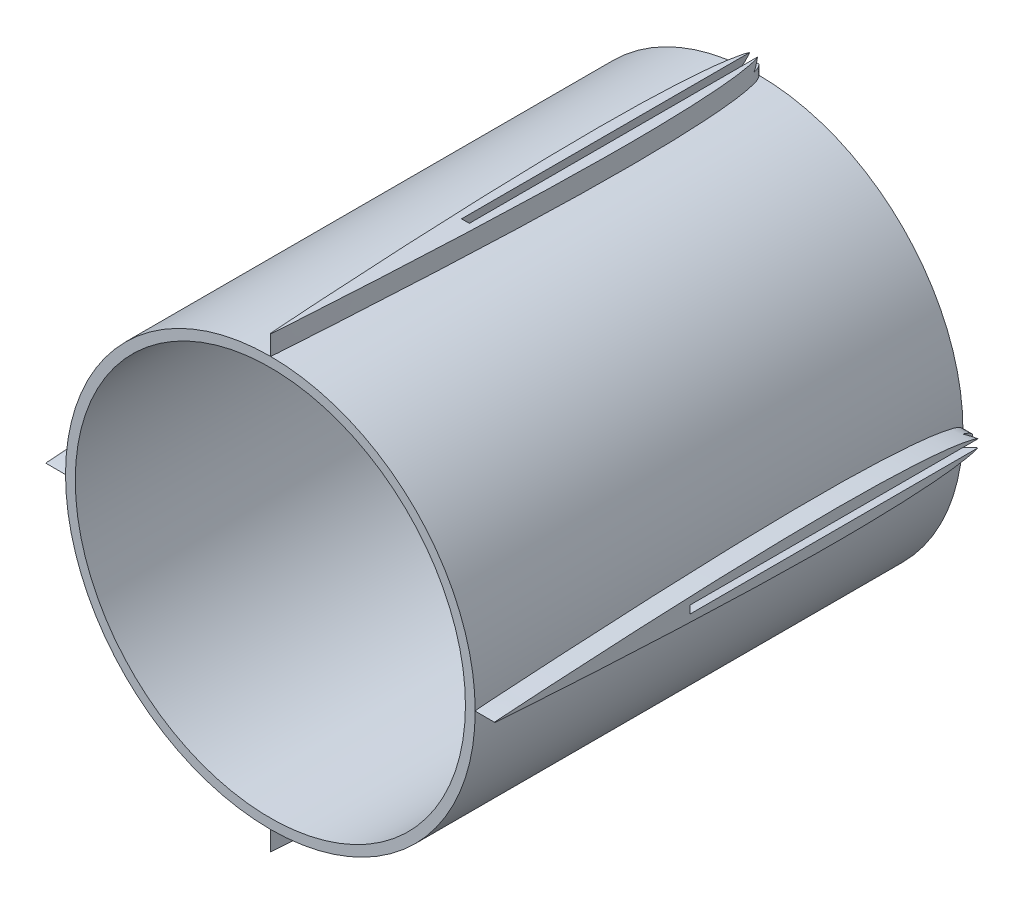
from build123d import *

# Parameters (mm, degrees)
SKETCH2_R           = 21
SKETCH2_R_2         = 20
BOSS_EXTRUDE1_DEPTH = 50
BOSS_EXTRUDE2_START = 23
BOSS_EXTRUDE2_DEPTH = 2.5
CUT_EXTRUDE1_DEPTH  = 30
CIRPATTERN1_COUNT   = 4


with BuildPart() as part:
    # Sketch2 → Boss-Extrude1 (new body)
    with BuildSketch(Plane.XY):
        Circle(SKETCH2_R)
        Circle(SKETCH2_R_2, mode=Mode.SUBTRACT)
    extrude(amount=BOSS_EXTRUDE1_DEPTH)

    # Sketch4 → Boss-Extrude2 (add)
    with BuildSketch(Plane(origin=(0, 0, 0), x_dir=(1, 0, 0), z_dir=(0, 1, 0)).offset(BOSS_EXTRUDE2_START)):
        with BuildLine():
            add(Edge.make_bspline(
                [(0, -50), (0.070574794, -50), (0.211641076, -47.125457824), (0.411982789, -44.384002629), (0.663217828, -39.927347093), (0.921106295, -35.020545166), (1.148106942, -29.995590241), (1.332253534, -25.002269837), (1.463720169, -20.000338655), (1.50961292, -15.833475854), (1.491450885, -12.499733372), (1.442100876, -9.999450324), (1.347002787, -7.497847023), (1.21482098, -5.415781084), (1.054842987, -3.745401607), (0.904008723, -2.503915111), (0.696273378, -1.421838007), (0.512523451, -0.628600997), (0, 0.343595251), (-0.512523451, -0.628600997), (-0.696273378, -1.421838007), (-0.904008723, -2.503915111), (-1.054842987, -3.745401607), (-1.21482098, -5.415781084), (-1.347002787, -7.497847023), (-1.442100876, -9.999450324), (-1.491450885, -12.499733372), (-1.50961292, -15.833475854), (-1.463720169, -20.000338655), (-1.332253534, -25.002269837), (-1.148106942, -29.995590241), (-0.921106295, -35.020545166), (-0.663217828, -39.927347093), (-0.411982789, -44.384002629), (-0.211641076, -47.125457824), (-0.070574794, -50), (0, -50)],
                knots=[0, 0, 0, 0, 0.024946615, 0.049863783, 0.099681635, 0.149480781, 0.199263062, 0.249028132, 0.298776252, 0.348510643, 0.373377067, 0.398248217, 0.423133292, 0.448054025, 0.460544649, 0.473080978, 0.485731774, 0.492200943, 0.5, 0.507799057, 0.514268226, 0.526919022, 0.539455351, 0.551945975, 0.576866708, 0.601751783, 0.626622933, 0.651489357, 0.701223748, 0.750971868, 0.800736938, 0.850519219, 0.900318365, 0.950136217, 0.975053385, 1, 1, 1, 1], degree=3))
        make_face()
    boss_extrude2 = extrude(amount=-BOSS_EXTRUDE2_DEPTH)

    # Sketch5 → Cut-Extrude1 (cut)
    with BuildSketch(Plane(origin=(0, 0, 0), x_dir=(-1, 0, 0), z_dir=(0, 0, -1))):
        Polygon((-0.4, 23), (0.4, 23), (0.6, 22), (-0.6, 22), align=None)
    cut_extrude1 = extrude(amount=-CUT_EXTRUDE1_DEPTH, mode=Mode.SUBTRACT)

    # CirPattern1: Boss-Extrude2, Cut-Extrude1 ×4 about axis
    cirpattern1_axis = Axis((0, 0, 50), (0, 0, -1))
    add([boss_extrude2.rotate(cirpattern1_axis, i * 360 / CIRPATTERN1_COUNT) for i in range(1, CIRPATTERN1_COUNT)])
    add([cut_extrude1.rotate(cirpattern1_axis, i * 360 / CIRPATTERN1_COUNT) for i in range(1, CIRPATTERN1_COUNT)], mode=Mode.SUBTRACT)


solid = part.part
